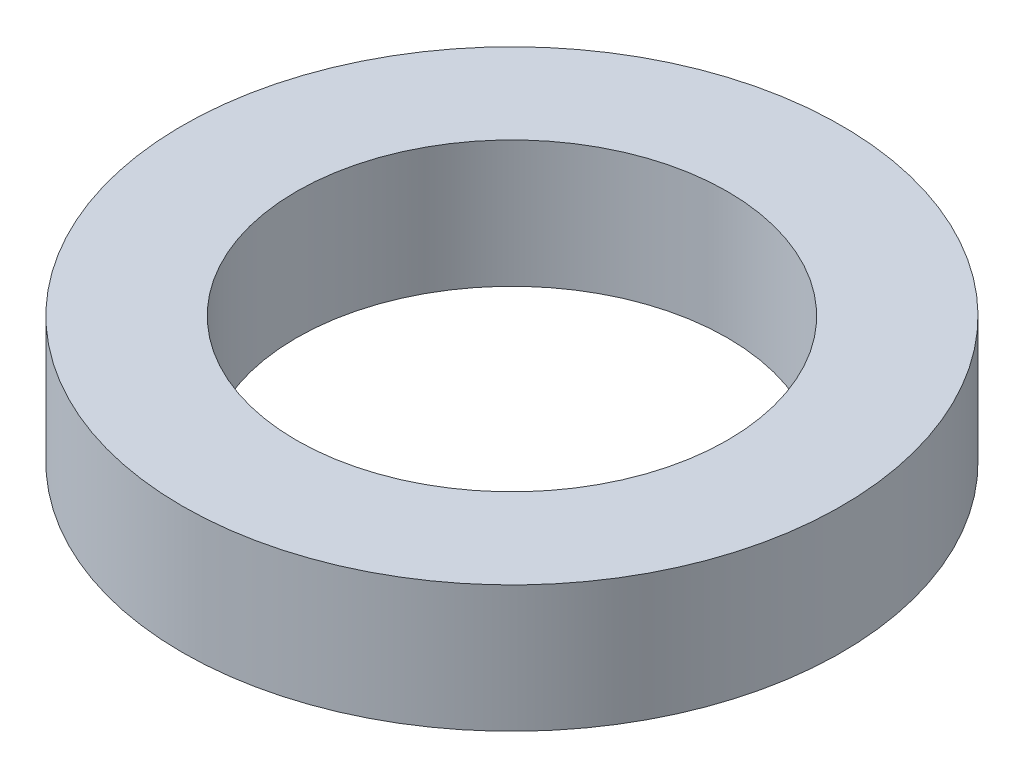
from build123d import *

# Parameters (mm, degrees)
SKETCH1_R           = 13
SKETCH1_R_2         = 8.5
BOSS_EXTRUDE1_DEPTH = 5


with BuildPart() as part:
    # Sketch1 → Boss-Extrude1 (new body)
    with BuildSketch(Plane(origin=(0, 0, 0), x_dir=(1, 0, 0), z_dir=(0, 1, 0))):
        Circle(SKETCH1_R)
        Circle(SKETCH1_R_2, mode=Mode.SUBTRACT)
    extrude(amount=BOSS_EXTRUDE1_DEPTH)


solid = part.part
